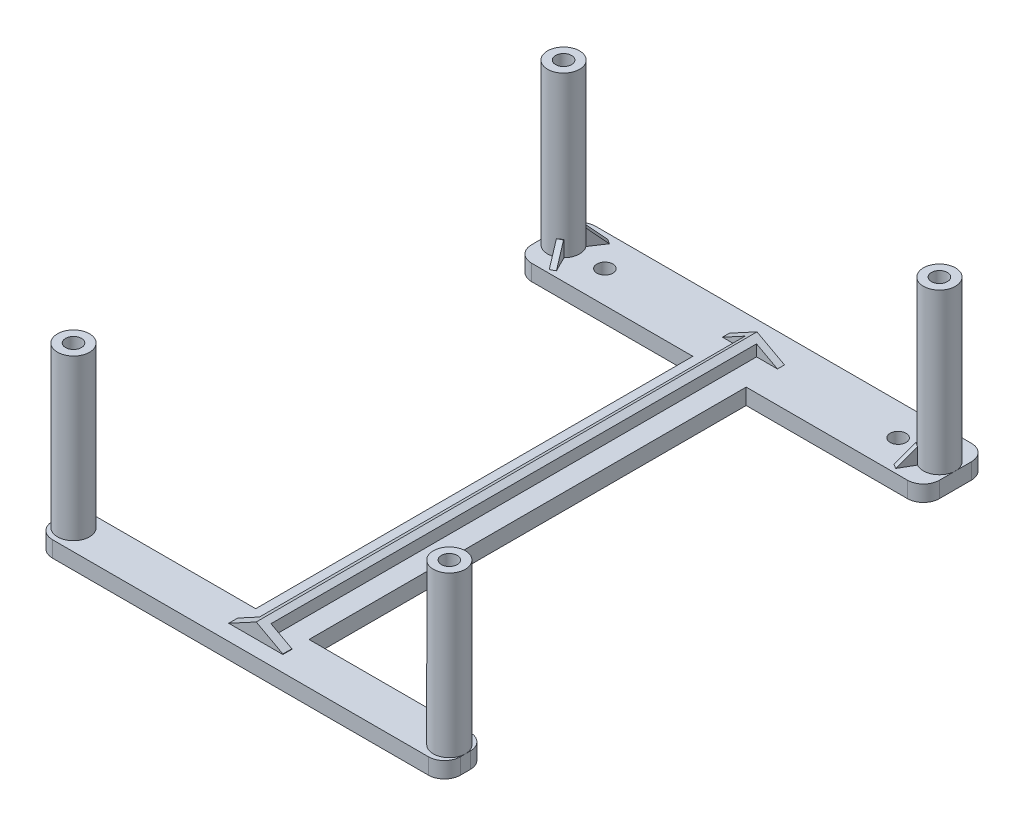
from build123d import *

# Parameters (mm, degrees)
SKETCH_1_W          = 70.5
SKETCH_1_H          = 12
SKETCH_1_R          = 1.5
EXTRUDE_2_DEPTH     = 4
SKETCH_3_W          = 10
SKETCH_3_H          = 82
EXTRUDE_3_DEPTH     = 3
EXTRUDE_4_DEPTH     = 3
SKETCH_5_W          = 70.5
SKETCH_5_H          = 12.216564443
CUT_EXTRUDE_1_DEPTH = 1
SKETCH_6_R          = 3
EXTRUDE_5_DEPTH     = 30
SKETCH_7_W          = 12
SKETCH_7_H          = 3
EXTRUDE_6_DEPTH     = 3
SKETCH_8_W          = 12
SKETCH_8_H          = 3
EXTRUDE_7_DEPTH     = 3
SKETCH_10_W         = 7.85
SKETCH_10_H         = 3
EXTRUDE_8_DEPTH     = 3
SKETCH_11_W         = 7.85
SKETCH_11_H         = 3
EXTRUDE_9_DEPTH     = 3
FILLET_1_R          = 3
EXTRUDE_10_DEPTH    = 3
SKETCH_26_R         = 1.5
CUT_EXTRUDE_2_DEPTH = 30
SKETCH_28_R         = 1.5
CUT_EXTRUDE_3_DEPTH = 30
SKETCH_30_R         = 1.5
CUT_EXTRUDE_4_DEPTH = 30
SKETCH_29_R         = 1.5
CUT_EXTRUDE_5_DEPTH = 30


with BuildPart() as part:
    # 草图1 → 凸台-拉伸2 (new body)
    with BuildSketch(Plane(origin=(0, 0, 0), x_dir=(1, 0, 0), z_dir=(0, 1, 0))):
        with Locations((-4.632001312, -3.115886014)):
            Rectangle(SKETCH_1_W, SKETCH_1_H)
        with Locations((-32.132001312, -3.115886014)):
            Circle(SKETCH_1_R, mode=Mode.SUBTRACT)
        with Locations((22.867998688, -3.115886014)):
            Circle(SKETCH_1_R, mode=Mode.SUBTRACT)
    extrude(amount=EXTRUDE_2_DEPTH)

    # 草图3 → 凸台-拉伸3 (add)
    with BuildSketch(Plane.XZ):
        with Locations((-4.632001312, 50.115886014)):
            Rectangle(SKETCH_3_W, SKETCH_3_H)
    extrude(amount=-EXTRUDE_3_DEPTH)

    # 草图4 → 凸台-拉伸4 (add)
    with BuildSketch(Plane(origin=(0, 3, 0), x_dir=(1, 0, 0), z_dir=(0, 1, 0))):
        Polygon((-4.632001312, -91.115886014), (-39.882001312, -91.115886014), (-39.882001312, -98.965886014), (30.617998688, -98.965886014), (30.617998688, -91.115886014), align=None)
    extrude(amount=-EXTRUDE_4_DEPTH)

    # 草图5 → 切除-拉伸1 (cut)
    with BuildSketch(Plane(origin=(0, 4, 0), x_dir=(1, 0, 0), z_dir=(0, 1, 0))):
        with Locations((-4.632001312, -3.224168236)):
            Rectangle(SKETCH_5_W, SKETCH_5_H)
    extrude(amount=-CUT_EXTRUDE_1_DEPTH, mode=Mode.SUBTRACT)

    # 草图6 → 凸台-拉伸5 (add)
    with BuildSketch(Plane(origin=(0, 3, 0), x_dir=(1, 0, 0), z_dir=(0, 1, 0))):
        with Locations((30.617998688, -3.115886014)):
            Circle(SKETCH_6_R)
        with Locations((-39.882001312, -3.115886014)):
            Circle(SKETCH_6_R)
        with Locations((30.617998688, -95.040886014)):
            Circle(SKETCH_6_R)
        with Locations((-39.882001312, -95.040886014)):
            Circle(SKETCH_6_R)
    extrude(amount=EXTRUDE_5_DEPTH)

    # 草图7 → 凸台-拉伸6 (add)
    with BuildSketch(Plane(origin=(30.617998688, 0, 0), x_dir=(0, 0, -1), z_dir=(1, 0, 0))):
        with Locations((-3.115886014, 1.5)):
            Rectangle(SKETCH_7_W, SKETCH_7_H)
    extrude(amount=EXTRUDE_6_DEPTH)

    # 草图8 → 凸台-拉伸7 (add)
    with BuildSketch(Plane.ZY.offset(39.882001312)):
        with Locations((3.115886014, 1.5)):
            Rectangle(SKETCH_8_W, SKETCH_8_H)
    extrude(amount=EXTRUDE_7_DEPTH)

    # 草图10 → 凸台-拉伸8 (add)
    with BuildSketch(Plane(origin=(30.617998688, 0, 0), x_dir=(0, 0, -1), z_dir=(1, 0, 0))):
        with Locations((-95.040886014, 1.5)):
            Rectangle(SKETCH_10_W, SKETCH_10_H)
    extrude(amount=EXTRUDE_8_DEPTH)

    # 草图11 → 凸台-拉伸9 (add)
    with BuildSketch(Plane.ZY.offset(39.882001312)):
        with Locations((95.040886014, 1.5)):
            Rectangle(SKETCH_11_W, SKETCH_11_H)
    extrude(amount=EXTRUDE_9_DEPTH)

    # 圆角1
    fillet_1_edges = [part.edges().sort_by_distance(p)[0] for p in [
        (-42.882001312, 1.5, 9.115886014),
        (-42.882001312, 1.5, -2.884113986),
        (33.617998688, 1.5, -2.884113986),
        (33.617998688, 1.5, 9.115886014),
        (33.617998688, 1.5, 91.115886014),
        (33.617998688, 1.5, 98.965886014),
        (-42.882001312, 1.5, 91.115886014),
        (-42.882001312, 1.5, 98.965886014),
    ]]
    fillet(fillet_1_edges, radius=FILLET_1_R)

    # 草图12 → 凸台-拉伸10 (add)
    with BuildSketch(Plane(origin=(0, 3, 0), x_dir=(1, 0, 0), z_dir=(0, 1, 0))):
        Polygon((-39.882001312, -3.115886014), (-36.574447776, 1.890119339), (-35.74011355, 1.338860417), (-38.729397599, -3.185441847), (-36.305878929, -8.036388905), (-37.200450273, -8.483314078), align=None)
        Polygon((30.617998688, -3.115886014), (27.617998688, 2.080266408), (26.800231701, 1.50471697), (29.487170484, -3.115886014), (26.765595108, -7.789153997), (27.617998688, -8.312038437), align=None)
        Polygon((-9.960523859, -3.236448921), (-5.714518795, -3.236448921), (-5.714518795, -94.31838866), (-9.960523859, -94.31838866), (-9.960523859, -96.014577306), (0.358950446, -96.014577306), (0.358950446, -94.31838866), (-3.561614819, -94.31838866), (-3.561614819, -3.236448921), (0.358950446, -3.236448921), (0.358950446, -1.92078538), (0, -1.92078538), (-9.960523859, -1.92078538), align=None)
    extrude(amount=EXTRUDE_10_DEPTH)

    # 切除-扫描1: sweep along a path in 草图14
    with BuildLine(Plane(origin=(-10.245146765, 0, 15.506101105), x_dir=(-0.834334226, 0, -0.551258923), z_dir=(0.551258923, 0, -0.834334226))) as sweep_1_path:
        Line((30.557258713, 3), (31.557258713, 3))
    # 草图13 → 切除-扫描1 (sweep, cut)
    with BuildSketch(Plane(origin=(-25.494966785, 0, -16.844961522), x_dir=(0.551258923, 0, -0.834334226), z_dir=(0.834334226, 0, 0.551258923))):
        Polygon((-21.756572303, 6), (-18.584999427, 3), (-18.584999427, 6), align=None)
    sweep(path=sweep_1_path.line, mode=Mode.SUBTRACT)

    # 切除-扫描2: sweep along a path in 草图16
    with BuildLine(Plane(origin=(-4.038812737, 0, -8.084141049), x_dir=(0.894571344, 0, -0.446925173), z_dir=(0.446925173, 0, 0.894571344))) as sweep_2_path:
        Line((-37.069863413, 3), (-36.069863413, 3))
    # 草图15 → 切除-扫描2 (sweep, cut)
    with BuildSketch(Plane(origin=(-33.161637535, 0, 16.567455127), x_dir=(0.446925173, 0, 0.894571344), z_dir=(-0.894571344, 0, 0.446925173))):
        Polygon((-12.036888006, 6), (-9.036888006, 3), (-9.036888006, 6), align=None)
    sweep(path=sweep_2_path.line, mode=Mode.SUBTRACT)

    # 切除-扫描3: sweep along a path in 草图18
    with BuildLine(Plane(origin=(8.169550431, 0, 11.607671187), x_dir=(-0.817766986, 0, 0.575549439), z_dir=(-0.575549439, 0, -0.817766986))) as sweep_3_path:
        Line((-23.782383716, 3), (-22.782383716, 3))
    # 草图17 → 切除-扫描3 (sweep, cut)
    with BuildSketch(Plane(origin=(21.614280794, 0, -12.479010835), x_dir=(-0.5, 0, -0.866025404), z_dir=(0.866025404, 0, -0.5))):
        Polygon((-15.007435787, 6), (-12.007435787, 3), (-12.007435787, 6), align=None)
    sweep(path=sweep_3_path.line, mode=Mode.SUBTRACT)

    # 切除-扫描4: sweep along a path in 草图20
    with BuildLine(Plane(origin=(3.846238842, 0, -6.270119175), x_dir=(0.852403579, 0, 0.52288444), z_dir=(-0.52288444, 0, 0.852403579))) as sweep_4_path:
        Line((27.887916501, 3), (26.887916501, 3))
    # 草图19 → 切除-扫描4 (sweep, cut)
    with BuildSketch(Plane(origin=(24.312717238, 0, 14.036953842), x_dir=(0.5, 0, -0.866025404), z_dir=(0.866025404, 0, 0.5))):
        Polygon((9.6105629, 6), (6.6105629, 3), (6.6105629, 6), align=None)
    sweep(path=sweep_4_path.line, mode=Mode.SUBTRACT)

    # 切除-扫描8: sweep along a path in 草图25
    with BuildLine(Plane(origin=(0, 3, 0), x_dir=(1, 0, 0), z_dir=(0, 1, 0))) as sweep_8_path:
        Line((-4.800786706, -1.92078538), (-4.632001312, -98.965886014))
    # 草图24 → 切除-扫描8 (sweep, cut)
    with BuildSketch(Plane(origin=(0, 0, 1.92078538), x_dir=(-1, 0, 0), z_dir=(0, 0, -1))):
        Polygon((-0.358950446, 3), (4.800786706, 5.789897824), (9.960523859, 3), (10.109613681, 3), (10.681927492, 3), (10.681927492, 6), (10.109613681, 6), (-0.358950446, 6), align=None)
    sweep(path=sweep_8_path.line, mode=Mode.SUBTRACT)

    # 草图26 → 切除-拉伸2 (cut)
    with BuildSketch(Plane(origin=(0, 33, 0), x_dir=(1, 0, 0), z_dir=(0, 1, 0))):
        with Locations((-39.882001312, -95.040886014)):
            Circle(SKETCH_26_R)
    extrude(amount=-CUT_EXTRUDE_2_DEPTH, mode=Mode.SUBTRACT)

    # 草图28 → 切除-拉伸3 (cut)
    with BuildSketch(Plane(origin=(0, 33, 0), x_dir=(1, 0, 0), z_dir=(0, 1, 0))):
        with Locations((30.617998688, -95.040886014)):
            Circle(SKETCH_28_R)
    extrude(amount=-CUT_EXTRUDE_3_DEPTH, mode=Mode.SUBTRACT)

    # 草图30 → 切除-拉伸4 (cut)
    with BuildSketch(Plane(origin=(0, 33, 0), x_dir=(1, 0, 0), z_dir=(0, 1, 0))):
        with Locations((30.617998688, -3.115886014)):
            Circle(SKETCH_30_R)
    extrude(amount=-CUT_EXTRUDE_4_DEPTH, mode=Mode.SUBTRACT)

    # 草图29 → 切除-拉伸5 (cut)
    with BuildSketch(Plane(origin=(0, 33, 0), x_dir=(1, 0, 0), z_dir=(0, 1, 0))):
        with Locations((-39.882001312, -3.115886014)):
            Circle(SKETCH_29_R)
    extrude(amount=-CUT_EXTRUDE_5_DEPTH, mode=Mode.SUBTRACT)


solid = part.part
